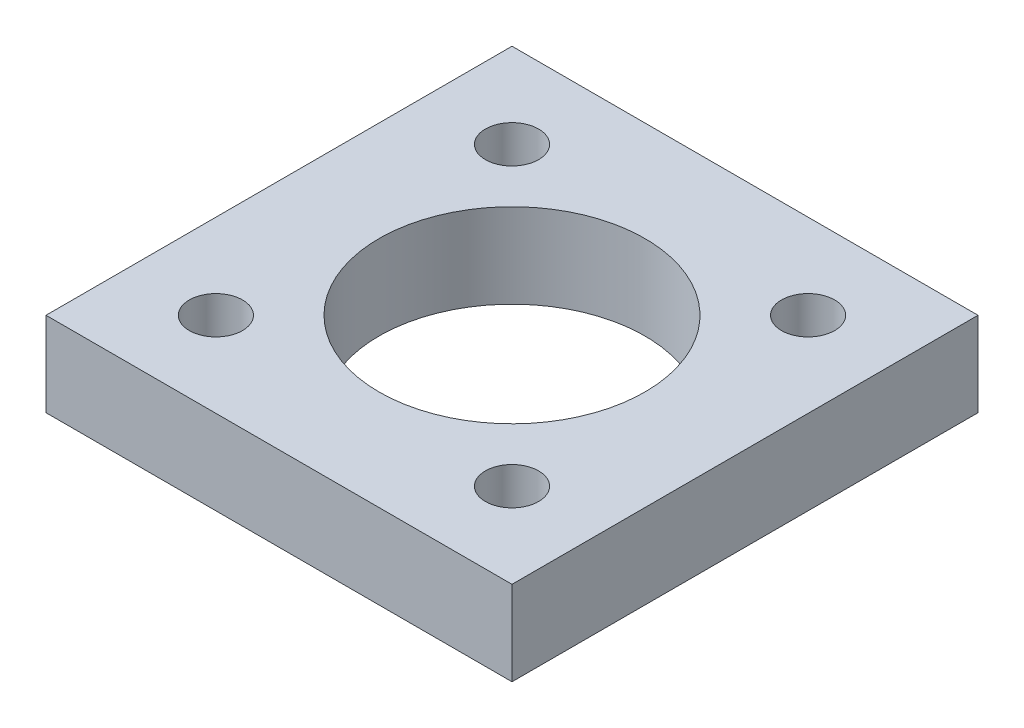
from build123d import *

# Parameters (mm, degrees)
SKETCH1_W           = 17.526
SKETCH1_H           = 17.526
SKETCH1_R           = 1
SKETCH1_R_2         = 5
BOSS_EXTRUDE1_DEPTH = 3.175


with BuildPart() as part:
    # Sketch1 → Boss-Extrude1 (new body)
    with BuildSketch(Plane(origin=(0, 0, 0), x_dir=(1, 0, 0), z_dir=(0, 1, 0))):
        Rectangle(SKETCH1_W, SKETCH1_H)
        with Locations((-5.567758795, 5.567758795)):
            Circle(SKETCH1_R, mode=Mode.SUBTRACT)
        with Locations((5.567758795, 5.567758795)):
            Circle(SKETCH1_R, mode=Mode.SUBTRACT)
        with Locations((5.567758795, -5.567758795)):
            Circle(SKETCH1_R, mode=Mode.SUBTRACT)
        with Locations((-5.567758795, -5.567758795)):
            Circle(SKETCH1_R, mode=Mode.SUBTRACT)
        Circle(SKETCH1_R_2, mode=Mode.SUBTRACT)
    extrude(amount=BOSS_EXTRUDE1_DEPTH)


solid = part.part
